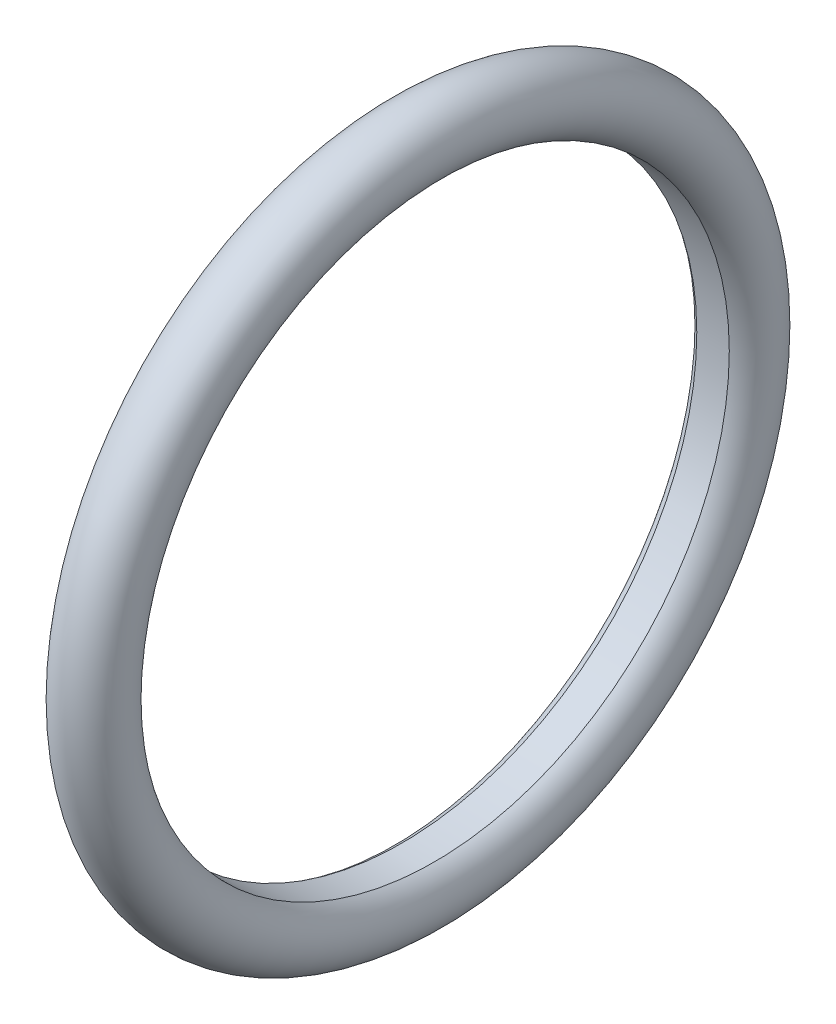
from build123d import *

# Parameters (mm, degrees)
SKETCH1_R          = 2
SKETCH2_R          = 17.575
CUT_EXTRUDE3_DEPTH = 1


with BuildPart() as part:
    # Sketch1 → Revolve1 (revolve)
    with BuildSketch(Plane.XY):
        with Locations((0, 19.325000244)):
            Circle(SKETCH1_R)
    revolve(axis=Axis((-1000, 0, 0), (1, 0, 0)))

    # Sketch2 → Cut-Extrude3 (cut, symmetric)
    with BuildSketch(Plane(origin=(0, 0, 0), x_dir=(0, 0, -1), z_dir=(1, 0, 0))):
        Circle(SKETCH2_R)
    extrude(amount=CUT_EXTRUDE3_DEPTH, both=True, mode=Mode.SUBTRACT)


solid = part.part
